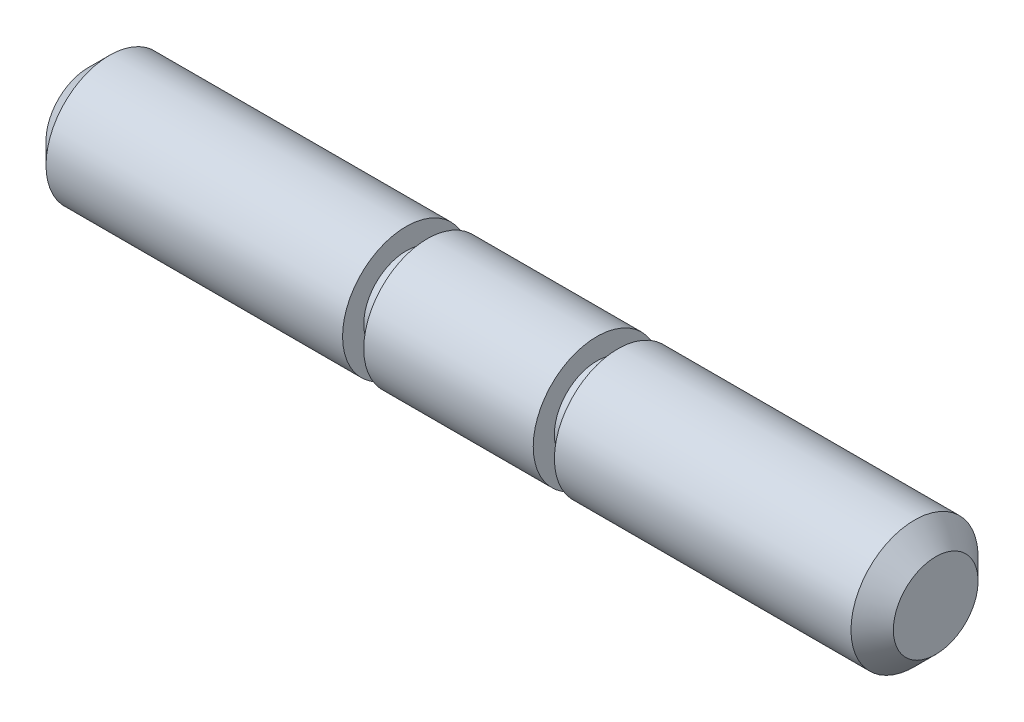
from build123d import *

# Parameters (mm, degrees)
CHAMFER1_SIZE = 0.5


with BuildPart() as part:
    # Sketch1 → Revolve1 (revolve)
    with BuildSketch(Plane.XY):
        Polygon((-10, 1.5), (-2.5, 1.5), (-2.5, 1), (-2, 1), (-2, 1.5), (2, 1.5), (2, 1), (2.5, 1), (2.5, 1.5), (10, 1.5), (10, 0), (-10, 0), align=None)
    revolve(axis=Axis((0, 0, 0), (1, 0, 0)))

    # Chamfer1
    chamfer1_edges = [part.edges().sort_by_distance(p)[0] for p in [
        (10, -1.5, 0),
        (-10, -1.5, 0),
    ]]
    chamfer(chamfer1_edges, length=CHAMFER1_SIZE)


solid = part.part
